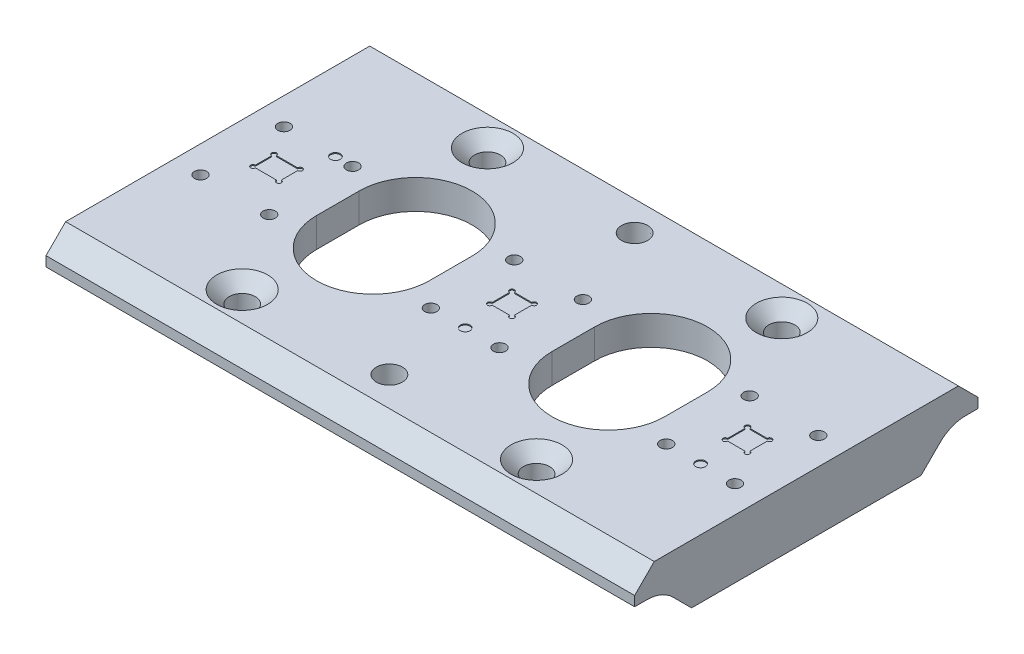
from build123d import *

# Parameters (mm, degrees)
SKETCH_5_W                  = 120
SKETCH_5_H                  = 70
EXTRUDE_2_DEPTH             = 6
SKETCH1_R                   = 1
CUT_EXTRUDE1_DEPTH          = 0.2
SKETCH2_R                   = 1
CUT_EXTRUDE2_DEPTH          = 0.2
HOLE_WIZARD_M51_D           = 5.3
HOLE_WIZARD_M51_CSINK_D     = 10.4
HOLE_WIZARD_M51_CSINK_ANGLE = 90
SKETCH5_R                   = 2.6
CUT_EXTRUDE4_DEPTH          = 10
CUT_EXTRUDE4_TAPER          = -0.573055556
CUT_EXTRUDE_1_DEPTH         = 7.0000001
EXTRUDE_3_DEPTH             = 120
SKETCH_8_W                  = 92
SKETCH_8_H                  = 35.619722669
CUT_EXTRUDE_2_DEPTH         = 71
CHAMFER_1_SIZE              = 4
M3X0_51_D                   = 2.5


with BuildPart() as part:
    # Эскиз5 → Бобышка-Вытянуть2 (new body)
    with BuildSketch(Plane(origin=(0, 0, 0), x_dir=(1, 0, 0), z_dir=(0, 1, 0))):
        with Locations((60, 0)):
            Rectangle(SKETCH_5_W, SKETCH_5_H)
    extrude(amount=-EXTRUDE_2_DEPTH)

    # Sketch1 → Cut-Extrude1 (cut)
    with BuildSketch(Plane(origin=(0, 0, 0), x_dir=(1, 0, 0), z_dir=(0, 1, 0))):
        with Locations((16, 8)):
            Circle(SKETCH1_R)
        with BuildLine():
            Line((9.86, -2.16), (14.14, -2.16))
            ThreePointArc((14.14, -2.16), (14.993553391, -2.513553391), (14.64, -1.66))
            Line((14.64, -1.66), (14.64, 1.66))
            ThreePointArc((14.64, 1.66), (14.993553391, 2.513553391), (14.14, 2.16))
            Line((14.14, 2.16), (9.86, 2.16))
            ThreePointArc((9.86, 2.16), (9.006446609, 2.513553391), (9.36, 1.66))
            Line((9.36, 1.66), (9.36, -1.66))
            ThreePointArc((9.36, -1.66), (9.006446609, -2.513553391), (9.86, -2.16))
        make_face()
    extrude(amount=-CUT_EXTRUDE1_DEPTH, mode=Mode.SUBTRACT)

    # Sketch2 → Cut-Extrude2 (cut)
    with BuildSketch(Plane(origin=(0, 0, 0), x_dir=(1, 0, 0), z_dir=(0, 1, 0))):
        with Locations((59.481, -9.027)):
            Circle(SKETCH2_R)
        with Locations((107.481, -9.027)):
            Circle(SKETCH2_R)
        with BuildLine():
            Line((57.74, 1.76), (57.74, -1.76))
            ThreePointArc((57.74, -1.76), (57.386446609, -2.613553391), (58.24, -2.26))
            Line((58.24, -2.26), (61.76, -2.26))
            ThreePointArc((61.76, -2.26), (62.613553391, -2.613553391), (62.26, -1.76))
            Line((62.26, -1.76), (62.26, 1.76))
            ThreePointArc((62.26, 1.76), (62.613553391, 2.613553391), (61.76, 2.26))
            Line((61.76, 2.26), (58.24, 2.26))
            ThreePointArc((58.24, 2.26), (57.386446609, 2.613553391), (57.74, 1.76))
        make_face()
        with BuildLine():
            Line((105.74, 1.76), (105.74, -1.76))
            ThreePointArc((105.74, -1.76), (105.386446609, -2.613553391), (106.24, -2.26))
            Line((106.24, -2.26), (109.76, -2.26))
            ThreePointArc((109.76, -2.26), (110.613553391, -2.613553391), (110.26, -1.76))
            Line((110.26, -1.76), (110.26, 1.76))
            ThreePointArc((110.26, 1.76), (110.613553391, 2.613553391), (109.76, 2.26))
            Line((109.76, 2.26), (106.24, 2.26))
            ThreePointArc((106.24, 2.26), (105.386446609, 2.613553391), (105.74, 1.76))
        make_face()
    extrude(amount=-CUT_EXTRUDE2_DEPTH, mode=Mode.SUBTRACT)

    # Зенковка для  винта с плоской головкой M51 (through all)
    with Locations(Plane(origin=(0, 0, 0), x_dir=(1, 0, 0), z_dir=(0, 1, 0))):
        with Locations((30, 25), (90, 25), (90, -25), (30, -25)):
            CounterSinkHole(HOLE_WIZARD_M51_D / 2, HOLE_WIZARD_M51_CSINK_D / 2, counter_sink_angle=HOLE_WIZARD_M51_CSINK_ANGLE)

    # Sketch5 → Cut-Extrude4 (cut)
    with BuildSketch(Plane.XZ.offset(6)):
        with Locations((60, 25)):
            Circle(SKETCH5_R)
        with Locations((60, -25)):
            Circle(SKETCH5_R)
    extrude(amount=-CUT_EXTRUDE4_DEPTH, taper=CUT_EXTRUDE4_TAPER, mode=Mode.SUBTRACT)

    # Эскиз6 → Вырез-Вытянуть1 (cut, through all)
    with BuildSketch(Plane(origin=(0, 0, 0), x_dir=(1, 0, 0), z_dir=(0, 1, 0))):
        with BuildLine():
            Line((95.5, 4.35), (95.5, -4.35))
            ThreePointArc((95.5, -4.35), (84, -15.85), (72.5, -4.35))
            Line((72.5, -4.35), (72.5, 4.35))
            ThreePointArc((72.5, 4.35), (84, 15.85), (95.5, 4.35))
        make_face()
        with BuildLine():
            Line((47.5, 4.35), (47.5, -4.35))
            ThreePointArc((47.5, -4.35), (36, -15.85), (24.5, -4.35))
            Line((24.5, -4.35), (24.5, 4.35))
            ThreePointArc((24.5, 4.35), (36, 15.85), (47.5, 4.35))
        make_face()
    extrude(amount=-CUT_EXTRUDE_1_DEPTH, mode=Mode.SUBTRACT)

    # Эскиз7 → Бобышка-Вытянуть3 (add, through all)
    with BuildSketch(Plane.ZY):
        with BuildLine():
            Line((-32.5, -6), (32.5, -6))
            ThreePointArc((32.5, -6), (29.629874257, -6.570903506), (27.196699141, -8.196699141))
            Line((27.196699141, -8.196699141), (23.393398282, -12))
            Line((23.393398282, -12), (-23.393398282, -12))
            Line((-23.393398282, -12), (-27.196699141, -8.196699141))
            ThreePointArc((-27.196699141, -8.196699141), (-29.629874257, -6.570903506), (-32.5, -6))
        make_face()
    extrude(amount=-EXTRUDE_3_DEPTH)

    # Эскиз8 → Вырез-Вытянуть2 (cut, through all)
    with BuildSketch(Plane(origin=(0, 0, -35), x_dir=(-1, 0, 0), z_dir=(0, 0, -1))):
        with Locations((-60, -23.809861335)):
            Rectangle(SKETCH_8_W, SKETCH_8_H)
    extrude(amount=-CUT_EXTRUDE_2_DEPTH, mode=Mode.SUBTRACT)

    # Фаска1
    chamfer_1_edges = [part.edges().sort_by_distance(p)[0] for p in [
        (60, 0, 35),
        (60, 0, -35),
    ]]
    chamfer(chamfer_1_edges, length=CHAMFER_1_SIZE)

    # Отверстие обработанное метчиком M3x0.51 (through all)
    with Locations(Plane(origin=(0, 0, 0), x_dir=(1, 0, 0), z_dir=(0, 1, 0))):
        with Locations((114.481, -9.027), (100.481, -9.027), (100.481, 7.973), (114.481, 7.973), (66.481, 7.973), (52.481, 7.973), (52.481, -9.027), (66.481, -9.027), (19.5, -9), (5.5, -9), (5.5, 8), (19.5, 8)):
            Hole(M3X0_51_D / 2)


solid = part.part
